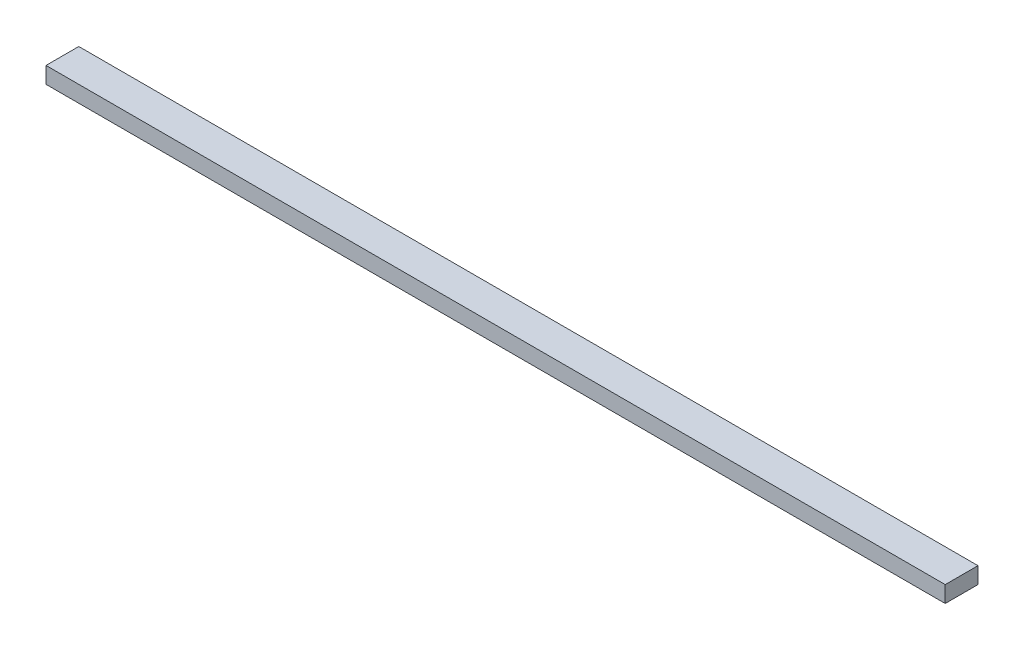
from build123d import *

# Parameters (mm, degrees)
SKETCH1_W           = 548.53
SKETCH1_H           = 20
BOSS_EXTRUDE1_DEPTH = 10


with BuildPart() as part:
    # Sketch1 → Boss-Extrude1 (new body)
    with BuildSketch(Plane(origin=(0, 0, 0), x_dir=(1, 0, 0), z_dir=(0, 1, 0))):
        Rectangle(SKETCH1_W, SKETCH1_H)
    extrude(amount=BOSS_EXTRUDE1_DEPTH)


solid = part.part
